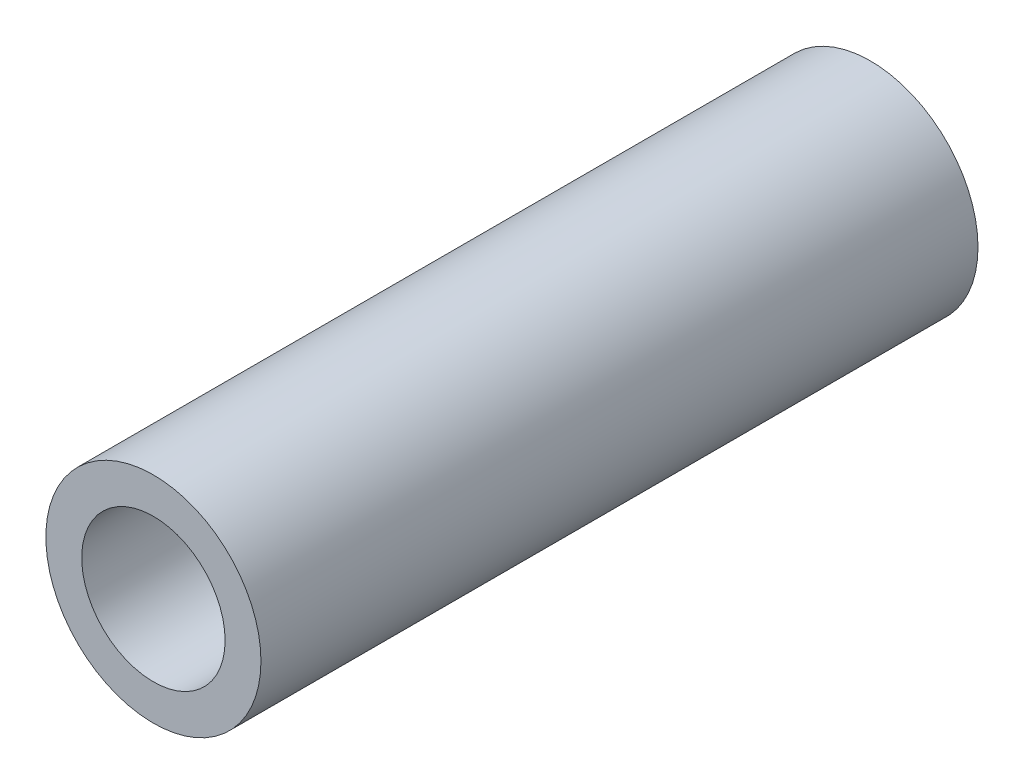
from build123d import *

# Parameters (mm, degrees)
SKETCH1_R           = 3
SKETCH1_R_2         = 2
BOSS_EXTRUDE1_DEPTH = 20
SKETCH1_2_R         = 2
BOSS_EXTRUDE2_DEPTH = 10


with BuildPart() as part:
    # Sketch1 → Boss-Extrude1 (new body)
    with BuildSketch(Plane.XY):
        Circle(SKETCH1_R)
        Circle(SKETCH1_R_2, mode=Mode.SUBTRACT)
    extrude(amount=BOSS_EXTRUDE1_DEPTH)

    # Sketch1_2 → Boss-Extrude2 (add)
    with BuildSketch(Plane.XY):
        Circle(SKETCH1_2_R)
    extrude(amount=BOSS_EXTRUDE2_DEPTH)


solid = part.part
